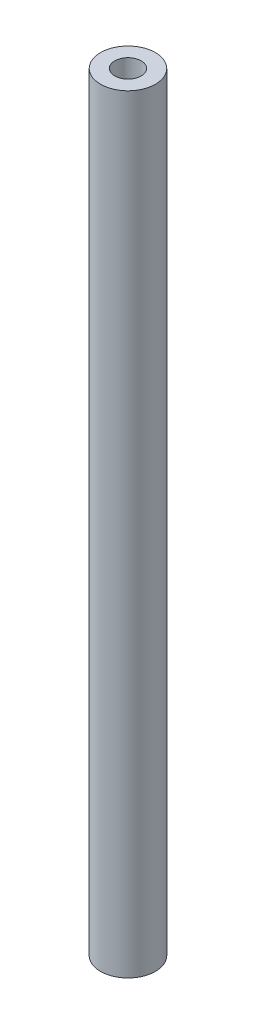
from build123d import *

# Parameters (mm, degrees)
SKETCH1_R           = 3.175
SKETCH1_R_2         = 1.524
BOSS_EXTRUDE1_DEPTH = 88.9


with BuildPart() as part:
    # Sketch1 → Boss-Extrude1 (new body)
    with BuildSketch(Plane(origin=(0, 0, 0), x_dir=(1, 0, 0), z_dir=(0, 1, 0))):
        Circle(SKETCH1_R)
        Circle(SKETCH1_R_2, mode=Mode.SUBTRACT)
    extrude(amount=BOSS_EXTRUDE1_DEPTH)


solid = part.part
